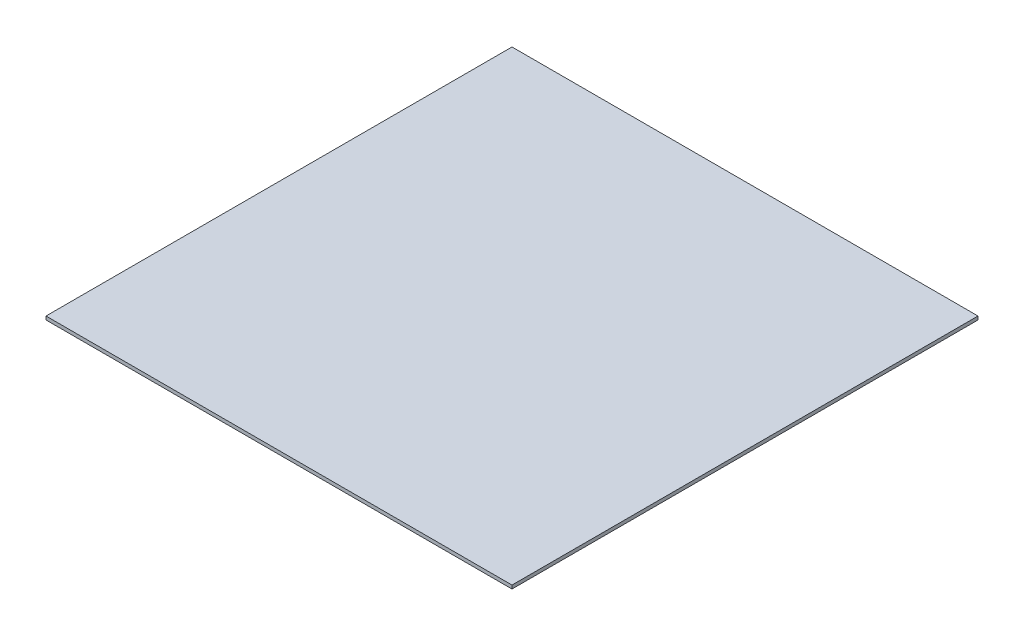
from build123d import *

# Parameters (mm, degrees)
SKETCH1_W           = 514.35
SKETCH1_H           = 514.35
BOSS_EXTRUDE1_DEPTH = 3.82


with BuildPart() as part:
    # Sketch1 → Boss-Extrude1 (new body)
    with BuildSketch(Plane(origin=(0, 0, 0), x_dir=(1, 0, 0), z_dir=(0, 1, 0))):
        Rectangle(SKETCH1_W, SKETCH1_H)
    extrude(amount=BOSS_EXTRUDE1_DEPTH)


solid = part.part
